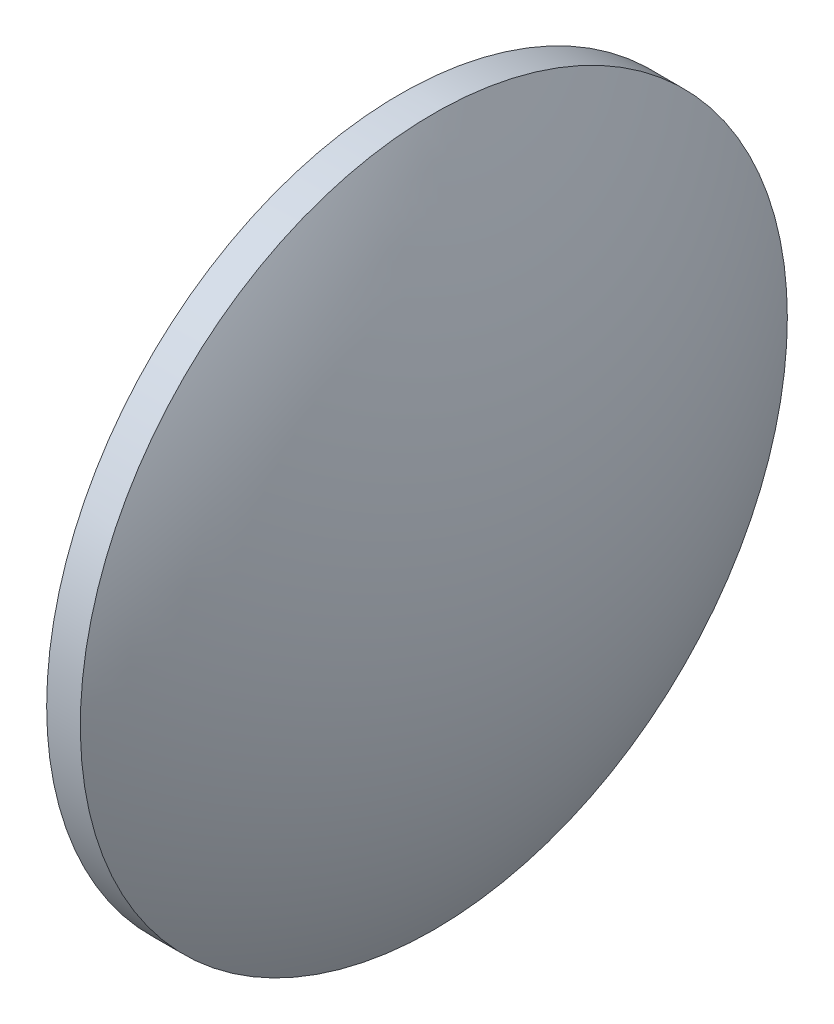
from build123d import *


with BuildPart() as part:
    # 草图1 → 旋转2 (revolve)
    with BuildSketch(Plane.XY, mode=Mode.PRIVATE) as revolve_2_sk:
        with BuildLine():
            Line((237.1753142, 130.467109853), (225.9653142, 130.467109853))
            Line((225.9653142, 130.467109853), (225.9653142, 161.967109853))
            Line((225.9653142, 161.967109853), (228.9653142, 161.967109853))
            ThreePointArc((228.9653142, 161.967109853), (235.089093263, 146.743274174), (237.1753142, 130.467109853))
        make_face()
    revolve(revolve_2_sk.sketch.rotate(Axis((237.1753142, 130.467109853, 0), (-1, 0, 0)), 180), axis=Axis((237.1753142, 130.467109853, 0), (-1, 0, 0)))  # turned: the seam where the file's is


solid = part.part
